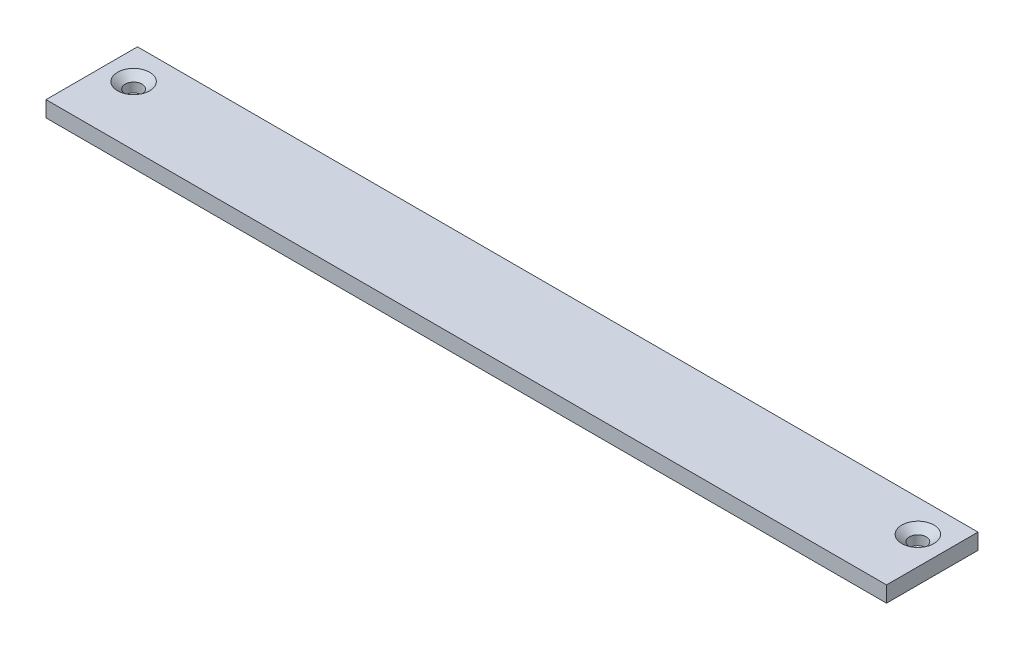
from build123d import *

# Parameters (mm, degrees)
SKETCH1_W                                           = 336.55
SKETCH1_H                                           = 47.625
BOSS_EXTRUDE1_DEPTH                                 = 3.175
CSK_FOR_1_4_FLAT_HEAD_MACHINE_SCREW_100_D           = 6.7564
CSK_FOR_1_4_FLAT_HEAD_MACHINE_SCREW_100_CSINK_D     = 12.8778
CSK_FOR_1_4_FLAT_HEAD_MACHINE_SCREW_100_CSINK_ANGLE = 100
SKETCH4_W                                           = 10.998522628
SKETCH4_H                                           = 6.35
CUT_EXTRUDE1_DEPTH                                  = 1
CUT_EXTRUDE1_DEPTH_BACK                             = 337.55


with BuildPart() as part:
    # Sketch1 → Boss-Extrude1 (new body, symmetric)
    with BuildSketch(Plane(origin=(0, 0, 0), x_dir=(1, 0, 0), z_dir=(0, 1, 0))):
        Rectangle(SKETCH1_W, SKETCH1_H)
    extrude(amount=BOSS_EXTRUDE1_DEPTH, both=True)

    # CSK for 1/4 Flat Head Machine Screw (100)1 (through all)
    with Locations(Plane(origin=(0, 3.175, 0), x_dir=(1, 0, 0), z_dir=(0, 1, 0))):
        with Locations((-157.00375, 0), (157.00375, 0)):
            CounterSinkHole(CSK_FOR_1_4_FLAT_HEAD_MACHINE_SCREW_100_D / 2, CSK_FOR_1_4_FLAT_HEAD_MACHINE_SCREW_100_CSINK_D / 2, counter_sink_angle=CSK_FOR_1_4_FLAT_HEAD_MACHINE_SCREW_100_CSINK_ANGLE)

    # Sketch4 → Cut-Extrude1 (cut, two sides)
    with BuildSketch(Plane.ZY.offset(168.275)) as cut_extrude1_sk:
        with Locations((-18.313238686, 0)):
            Rectangle(SKETCH4_W, SKETCH4_H)
    extrude(amount=CUT_EXTRUDE1_DEPTH, mode=Mode.SUBTRACT)
    extrude(cut_extrude1_sk.sketch, amount=-CUT_EXTRUDE1_DEPTH_BACK, mode=Mode.SUBTRACT)


solid = part.part
